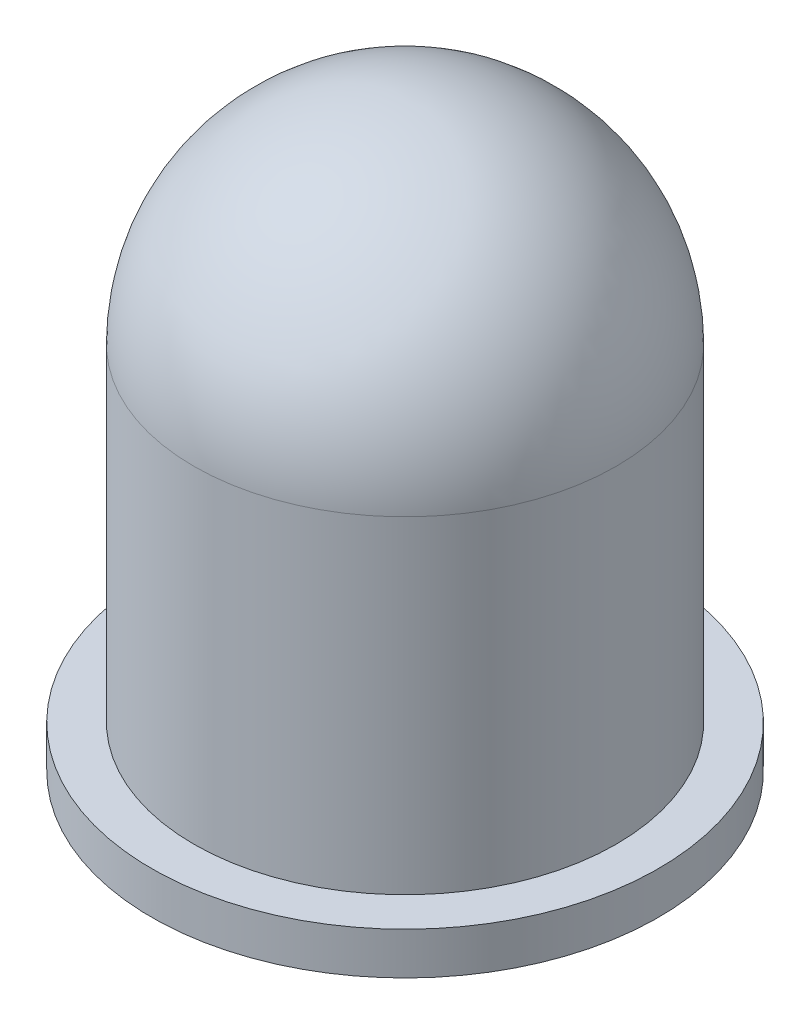
from build123d import *


with BuildPart() as part:
    # Sketch1 → Revolve1 (revolve)
    with BuildSketch(Plane.XY):
        with BuildLine():
            Line((0, 0), (4.8, 0))
            Line((4.8, 0), (4.8, 0.8))
            Line((4.8, 0.8), (4, 0.8))
            Line((4, 0.8), (4, 7))
            ThreePointArc((4, 7), (2.828427125, 9.828427125), (0, 11))
            Line((0, 11), (0, 0))
        make_face()
    revolve(axis=Axis((0, 0, 0), (0, 1, 0)))


solid = part.part
